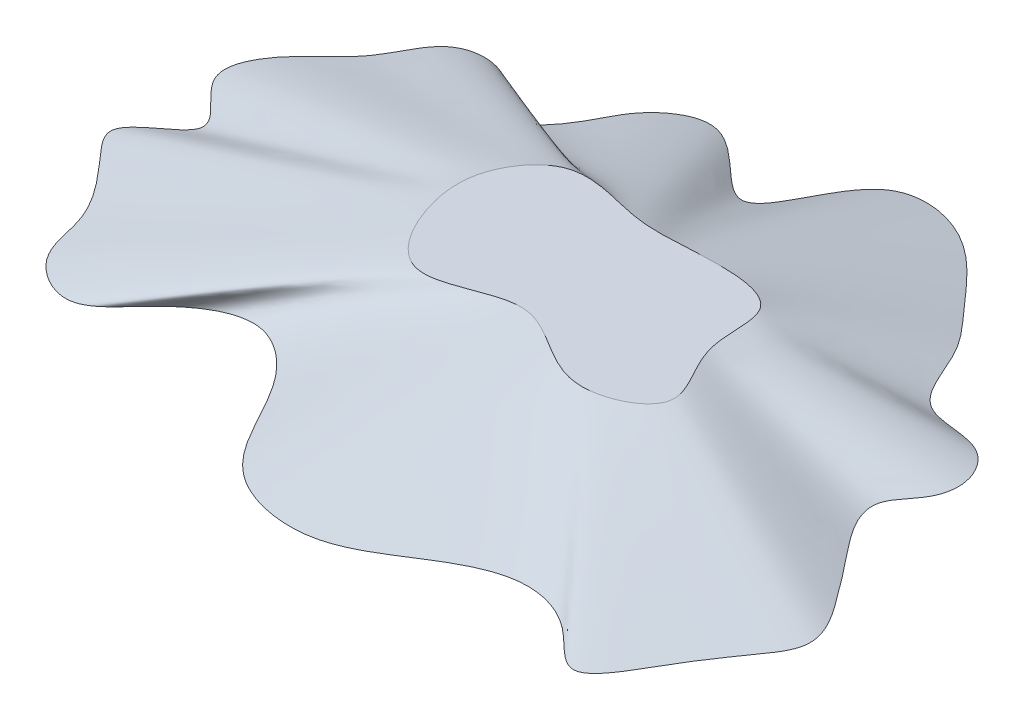
from build123d import *


with BuildPart() as part:
    # Sketch2 → Loft2 section 0
    with BuildSketch(Plane(origin=(0, 0, 0), x_dir=(1, 0, 0), z_dir=(0, 1, 0))):
        with BuildLine():
            add(Edge.make_bspline(
                [(-95.228464869, -15.201377637), (-95.073606469, -10.99909471), (-76.679019935, -4.082394238), (-97.688491741, 6.541963252), (-90.633979974, 22.05177223), (-79.002428462, 29.171780561), (-74.078324852, 44.634440486), (-58.345307392, 45.231387347), (-50.625867973, 30.254289837), (-40.733155866, 42.177772249), (-37.202284377, 51.940837821), (-21.289608341, 63.451426553), (-3.072554299, 33.026131759), (3.964590958, 68.549664017), (29.070117954, 66.712889891), (40.318722577, 52.219717831), (52.604122056, 39.374597673), (56.527630488, 21.891513073), (73.581182243, 24.919625859), (79.85719961, 14.723117654), (78.304892111, 6.218527945), (69.185635625, -1.850836236), (79.961724402, -15.221619429), (87.890986699, -25.321561703), (95.925200376, -37.123302953), (89.201371891, -46.880823152), (83.375711843, -54.936534386), (78.851856139, -63.387105452), (70.951883049, -75.201143579), (60.602624353, -61.325980485), (44.667118785, -57.398122718), (28.824718542, -67.143586675), (12.720267057, -77.751874928), (-15.458401585, -72.302583085), (-19.960351023, -47.488219172), (-39.429244391, -34.801094216), (-53.606224083, -44.309666212), (-63.932190208, -58.851947801), (-78.577280167, -49.962199022), (-79.98063062, -34.455980382), (-88.11144957, -25.35134149), (-95.299929213, -17.140655025), (-95.228464869, -15.201377637)],
                knots=[0, 0, 0, 0, 0.025836565, 0.052027072, 0.070243288, 0.09939833, 0.123093481, 0.142833092, 0.165491383, 0.183417181, 0.20130184, 0.224727342, 0.262345949, 0.304235377, 0.329157724, 0.373003829, 0.393177127, 0.422470793, 0.447241207, 0.463072261, 0.475277746, 0.489381765, 0.517811704, 0.541071541, 0.56434325, 0.578736439, 0.5969476, 0.615419794, 0.632111481, 0.652466524, 0.681115037, 0.712225641, 0.742741616, 0.779098152, 0.836614907, 0.854871514, 0.887306438, 0.911770155, 0.934444694, 0.953442735, 0.988076894, 1, 1, 1, 1], degree=3))
        make_face()
    # Sketch3 → Loft2 section 1
    with BuildSketch(Plane(origin=(0, 12.7, 0), x_dir=(1, 0, 0), z_dir=(0, 1, 0))):
        with BuildLine():
            add(Edge.make_bspline(
                [(-29.575673028, -3.528270253), (-30.620643979, 0.877793917), (-30.712637421, 8.986737203), (-20.238469108, 22.684313928), (-2.471617774, 15.16979934), (13.293039091, 17.208113179), (35.167628776, 16.59454319), (30.829771679, -3.11660305), (45.583137969, -17.978513343), (20.741339801, -29.879597804), (5.509303718, -8.159011886), (-19.090160545, -26.938446495), (-27.881486473, -10.671717319), (-29.575673028, -3.528270253)],
                knots=[0, 0, 0, 0, 0.065471346, 0.130017965, 0.229536302, 0.315425515, 0.407699276, 0.485529555, 0.573499411, 0.652171411, 0.783945822, 0.893852864, 1, 1, 1, 1], degree=3))
        make_face()
    loft()


solid = part.part
